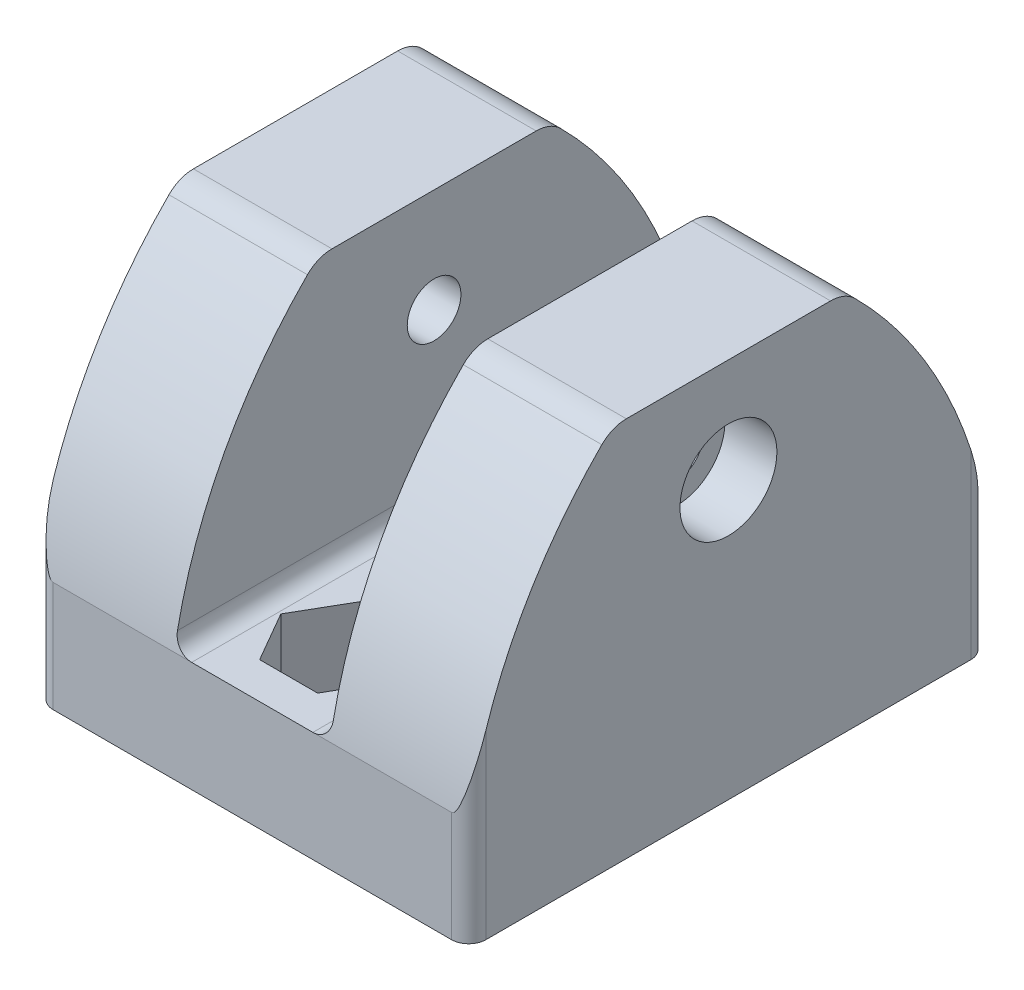
from build123d import *

# Parameters (mm, degrees)
CROQUIS1_W              = 25
CROQUIS1_H              = 30
CROQUIS1_R              = 1.55
SALIENTE_EXTRUIR1_DEPTH = 22
CROQUIS2_W              = 9
CROQUIS2_H              = 15.632666969
CORTAR_EXTRUIR1_DEPTH   = 30
CROQUIS3_R              = 1.55
CORTAR_EXTRUIR2_DEPTH   = 25
CORTAR_EXTRUIR3_DEPTH   = 2.5
CROQUIS5_R              = 2.8
CORTAR_EXTRUIR4_DEPTH   = 3
CORTAR_EXTRUIR5_DEPTH   = 4.5
CORTAR_EXTRUIR6_DEPTH   = 25
REDONDEO1_R             = 2
REDONDEO2_R             = 1
REDONDEO3_R             = 1


with BuildPart() as part:
    # Croquis1 → Saliente-Extruir1 (new body)
    with BuildSketch(Plane(origin=(0, 0, 0), x_dir=(1, 0, 0), z_dir=(0, 1, 0))):
        with Locations((12.5, 15)):
            Rectangle(CROQUIS1_W, CROQUIS1_H)
        with Locations((12.5, 25)):
            Circle(CROQUIS1_R, mode=Mode.SUBTRACT)
        with Locations((12.5, 5)):
            Circle(CROQUIS1_R, mode=Mode.SUBTRACT)
    extrude(amount=SALIENTE_EXTRUIR1_DEPTH)

    # Croquis2 → Cortar-Extruir1 (cut)
    with BuildSketch(Plane(origin=(0, 0, -30), x_dir=(-1, 0, 0), z_dir=(0, 0, -1))):
        with Locations((-12.5, 14.183666516)):
            Rectangle(CROQUIS2_W, CROQUIS2_H)
    extrude(amount=-CORTAR_EXTRUIR1_DEPTH, mode=Mode.SUBTRACT)

    # Croquis3 → Cortar-Extruir2 (cut)
    with BuildSketch(Plane.ZY):
        with Locations((-15, 16)):
            Circle(CROQUIS3_R)
    extrude(amount=-CORTAR_EXTRUIR2_DEPTH, mode=Mode.SUBTRACT)

    # Croquis4 → Cortar-Extruir3 (cut)
    with BuildSketch(Plane.ZY):
        Polygon((-14.967896351, 19.348477667), (-17.8838149, 17.702041409), (-17.915918548, 14.353563741), (-15.032103649, 12.651522333), (-12.1161851, 14.297958591), (-12.084081452, 17.646436259), align=None)
    extrude(amount=-CORTAR_EXTRUIR3_DEPTH, mode=Mode.SUBTRACT)

    # Croquis5 → Cortar-Extruir4 (cut)
    with BuildSketch(Plane(origin=(25, 0, 0), x_dir=(0, 0, -1), z_dir=(1, 0, 0))):
        with Locations((15, 16)):
            Circle(CROQUIS5_R)
    extrude(amount=-CORTAR_EXTRUIR4_DEPTH, mode=Mode.SUBTRACT)

    # Croquis6 → Cortar-Extruir5 (cut)
    with BuildSketch(Plane(origin=(0, 6.367333031, 0), x_dir=(1, 0, 0), z_dir=(0, 1, 0))):
        Polygon((15.848631561, 25), (14.174315781, 27.9), (10.825684219, 27.9), (9.151368439, 25), (10.825684219, 22.1), (14.174315781, 22.1), align=None)
        Polygon((15.848631561, 5), (14.174315781, 7.9), (10.825684219, 7.9), (9.151368439, 5), (10.825684219, 2.1), (14.174315781, 2.1), align=None)
    extrude(amount=-CORTAR_EXTRUIR5_DEPTH, mode=Mode.SUBTRACT)

    # Croquis7 → Cortar-Extruir6 (cut)
    with BuildSketch(Plane.ZY):
        with BuildLine():
            Line((-21.708203932, 22), (-30, 22))
            Line((-30, 22), (-30, 6.37))
            ThreePointArc((-30, 6.37), (-27.145099003, 14.869880624), (-21.708203932, 22))
        make_face()
        with BuildLine():
            Line((0, 22), (-8.291796068, 22))
            ThreePointArc((-8.291796068, 22), (-2.854900997, 14.869880624), (0, 6.37))
            Line((0, 6.37), (0, 22))
        make_face()
    extrude(amount=-CORTAR_EXTRUIR6_DEPTH, mode=Mode.SUBTRACT)

    # Redondeo1
    redondeo1_edges = [part.edges().sort_by_distance(p)[0] for p in [
        (4, 22, -21.708203932),
        (21, 22, -21.708203932),
        (4, 22, -8.291796068),
        (21, 22, -8.291796068),
    ]]
    fillet(redondeo1_edges, radius=REDONDEO1_R)

    # Redondeo2
    redondeo2_edges = [part.edges().sort_by_distance(p)[0] for p in [
        (17, 6.367333031, -15),
        (8, 6.367333031, -15),
    ]]
    fillet(redondeo2_edges, radius=REDONDEO2_R)

    # Redondeo3
    redondeo3_edges = [part.edges().sort_by_distance(p)[0] for p in [
        (25, 3.185, -30),
        (0, 3.185, -30),
        (25, 3.185, 0),
        (0, 3.185, 0),
    ]]
    fillet(redondeo3_edges, radius=REDONDEO3_R)


solid = part.part
